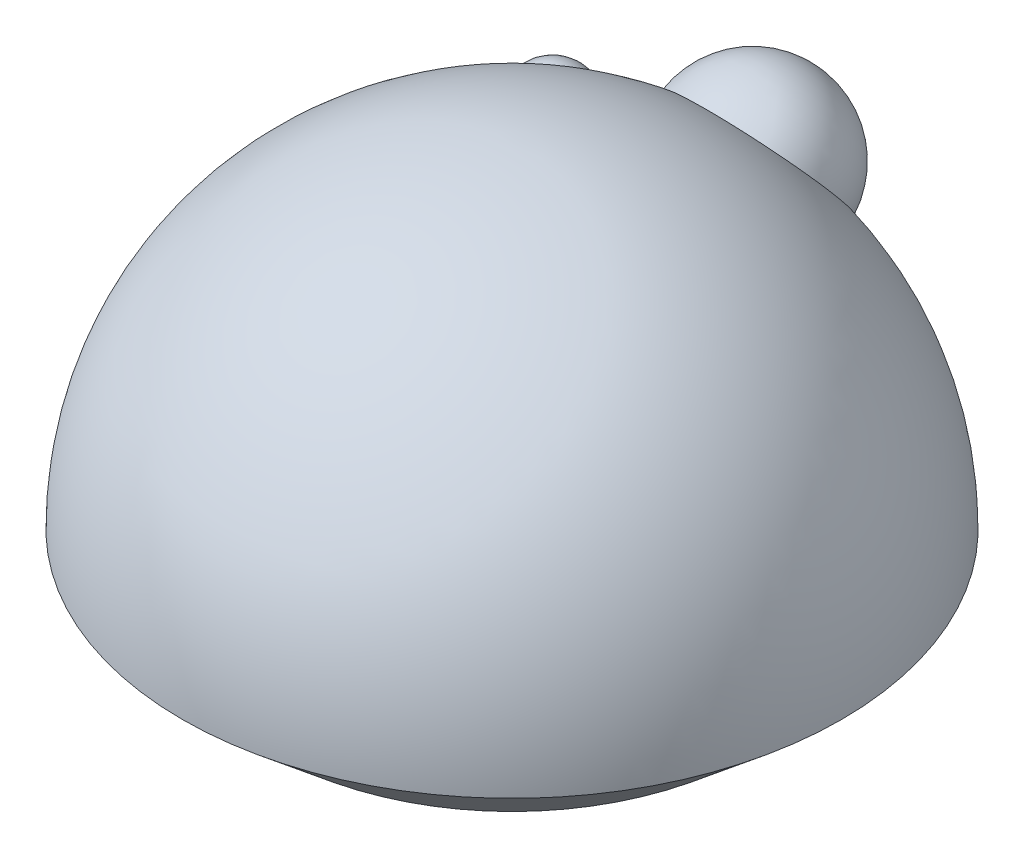
from build123d import *


with BuildPart() as part:
    # 草图1 → 旋转1 (revolve)
    with BuildSketch(Plane.XY):
        with BuildLine():
            Line((-75, 129.232052778), (-54.801890605, 112.34657443))
            ThreePointArc((-54.801890605, 112.34657443), (-28.12186157, 121.795570124), (0, 125))
            Line((0, 125), (0, 204.232052778))
            ThreePointArc((0, 204.232052778), (-53.033008589, 182.265061367), (-75, 129.232052778))
        make_face()
    revolve(axis=Axis((0, 213.081349398, 0), (0, -1, 0)))

    # 草图6 → 旋转2 (revolve)
    with BuildSketch(Plane(origin=(0, 0, 0), x_dir=(0, 0, -1), z_dir=(1, 0, 0))):
        with BuildLine():
            Line((36.229745399, 174.39946224), (73.229745399, 174.39946224))
            ThreePointArc((73.229745399, 174.39946224), (54.729745399, 192.89946224), (36.229745399, 174.39946224))
        make_face()
    revolve(axis=Axis((0, 174.39946224, 0), (0, 0, -1)))

    # 草图9 → 旋转4 (revolve)
    with BuildSketch(Plane(origin=(0, 0, 0), x_dir=(0, 1, 0), z_dir=(-0.7665183822714032, 0, 0.6422223677512571))):
        with BuildLine():
            Line((156.556180661, 65.879169876), (163.258797924, 82.039351206))
            ThreePointArc((163.258797924, 82.039351206), (156.56373545, 82.042480502), (151.827398627, 77.310569172))
            Line((151.827398627, 77.310569172), (148.476089996, 69.230478507))
            Line((148.476089996, 69.230478507), (156.556180661, 65.879169876))
        make_face()
    revolve(axis=Axis((0, 129.232052778, 0), (-0.5932211633183806, 0.3831152150832898, -0.7080334620361328)))

    # 草图15 → 旋转5 (revolve)
    with BuildSketch(Plane.XY):
        with BuildLine():
            Line((0, 125), (0, -125))
            ThreePointArc((0, -125), (125, 0), (0, 125))
        make_face()
    revolve(axis=Axis((0, 143.905509185, 0), (0, -1, 0)))

    # 草图15<3> → 切除-旋转5 (revolve, cut)
    with BuildSketch(Plane.XY):
        with BuildLine():
            Line((0, 125), (0, -125))
            ThreePointArc((0, -125), (125, 0), (0, 125))
        make_face()
    revolve(axis=Axis((0, 143.905509185, 0), (0, -1, 0)), mode=Mode.SUBTRACT)


solid = part.part
